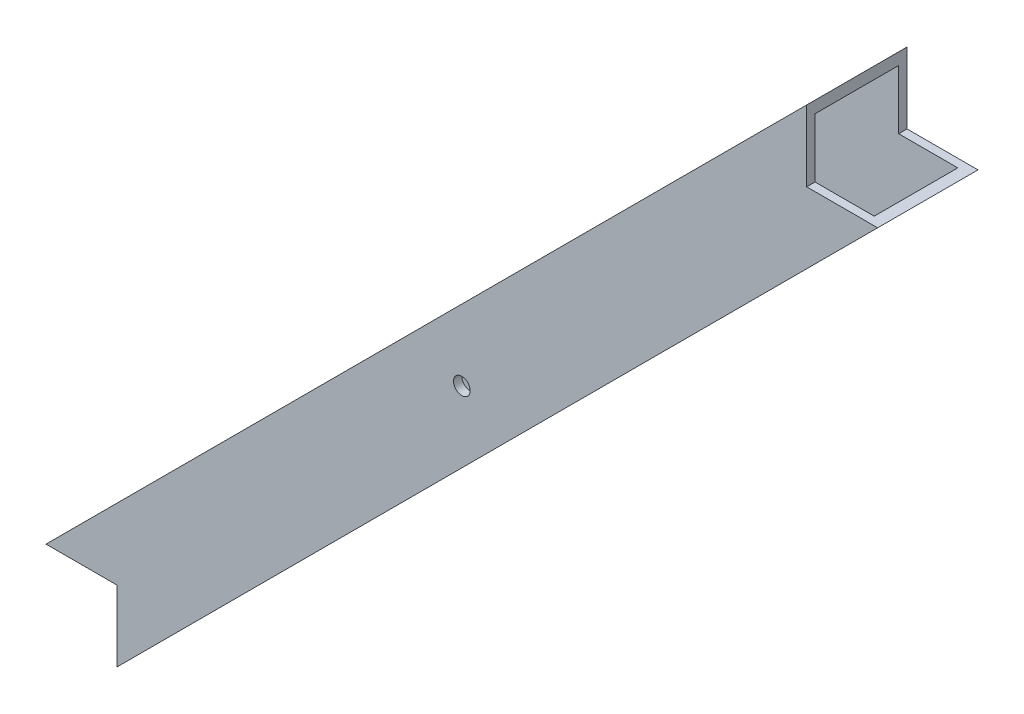
from build123d import *

# Parameters (mm, degrees)
SKETCH1_R               = 3.175
BOSS_EXTRUDE1_DEPTH     = 38.1
SKETCH3_W               = 31.75
SKETCH3_H               = 31.75
CUT_EXTRUDE1_DEPTH      = 224.291265993
CUT_EXTRUDE1_DEPTH_BACK = 224.291265993


with BuildPart() as part:
    # Sketch1 → Boss-Extrude1 (new body)
    with BuildSketch(Plane.XY):
        Polygon((19.05, -7.890768363), (307.890768363, 280.95), (280.95, 280.95), (280.95, 307.890768363), (-7.890768363, 19.05), (19.05, 19.05), align=None)
        with Locations((150, 150)):
            Circle(SKETCH1_R, mode=Mode.SUBTRACT)
    extrude(amount=-BOSS_EXTRUDE1_DEPTH)

    # Sketch3 → Cut-Extrude1 (cut, two sides)
    with BuildSketch(Plane(origin=(150, 150, 0), x_dir=(-0.707106781, 0.707106781, 0), z_dir=(-0.707106781, -0.707106781, 0))) as cut_extrude1_sk:
        with Locations((0, 19.05)):
            Rectangle(SKETCH3_W, SKETCH3_H)
    extrude(amount=CUT_EXTRUDE1_DEPTH, mode=Mode.SUBTRACT)
    extrude(cut_extrude1_sk.sketch, amount=-CUT_EXTRUDE1_DEPTH_BACK, mode=Mode.SUBTRACT)


solid = part.part
